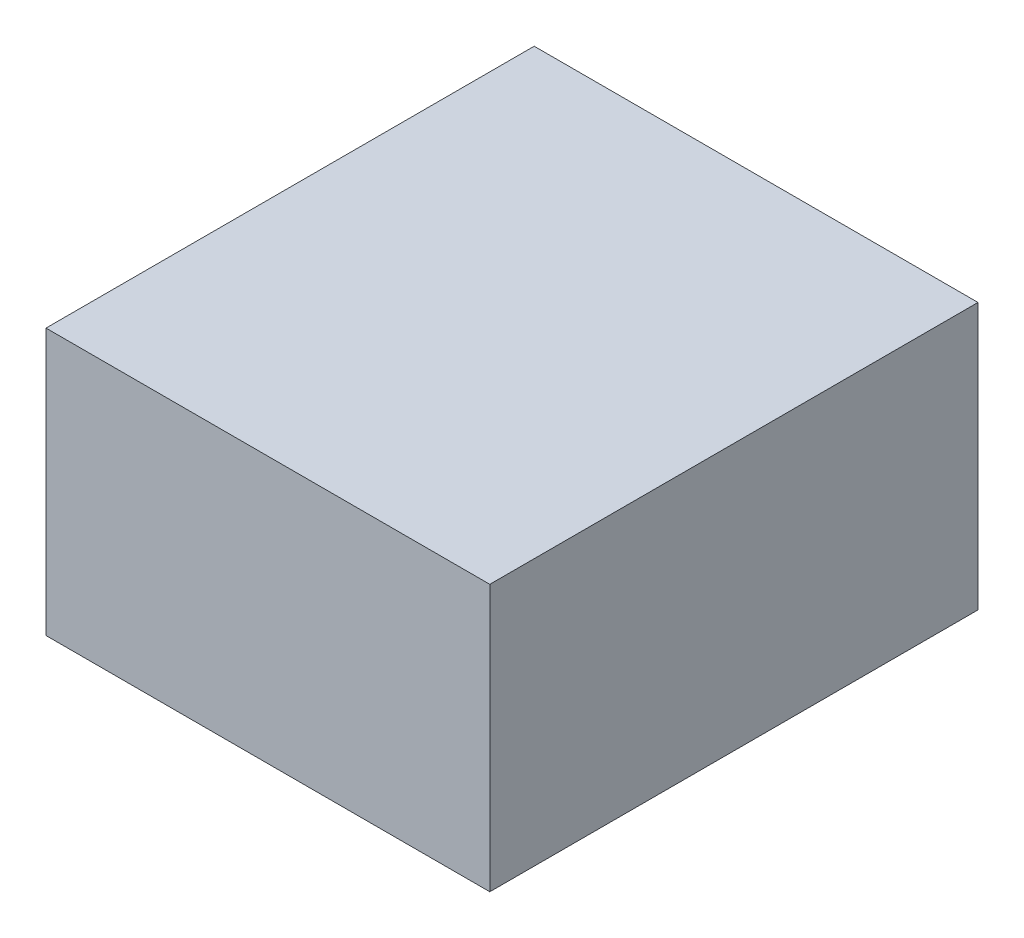
from build123d import *

# Parameters (mm, degrees)
SCHIZZO1_W                   = 100
SCHIZZO1_H                   = 60
ESTRUSIONE_ESTRUSIONE1_DEPTH = 110


with BuildPart() as part:
    # Schizzo1 → Estrusione-Estrusione1 (new body)
    with BuildSketch(Plane.XY):
        Rectangle(SCHIZZO1_W, SCHIZZO1_H)
    extrude(amount=ESTRUSIONE_ESTRUSIONE1_DEPTH)


solid = part.part
